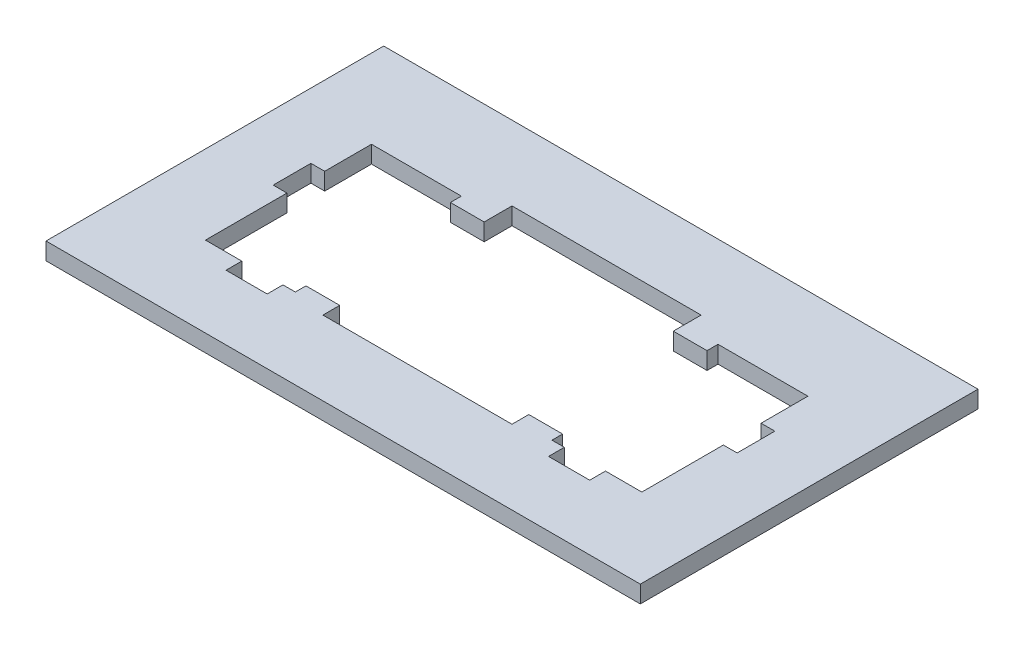
from build123d import *

# Parameters (mm, degrees)
SKETCH1_W           = 44
SKETCH1_H           = 25
BOSS_EXTRUDE1_DEPTH = 1.524
CHAMFER1_SIZE       = 0.25


with BuildPart() as part:
    # Sketch1 → Boss-Extrude1 (new body)
    with BuildSketch(Plane(origin=(0, 0, 0), x_dir=(1, 0, 0), z_dir=(0, 1, 0))):
        Rectangle(SKETCH1_W, SKETCH1_H)
        Polygon((-9.4996, 4.939226775), (-7, 4.939226775), (-7, 7), (7, 7), (7, 4.939226775), (9.4996, 4.939226775), (9.4996, 5.752026775), (16.1544, 5.752026775), (16.1544, 2.286), (17.174185585, 2.286), (17.174185585, -0.508), (16.1544, -0.508), (16.1544, -6.541573225), (13.462, -6.541573225), (13.462, -7.709973225), (10.414, -7.709973225), (10.414, -6.541573225), (9.4996, -6.541573225), (9.4996, -5.754173225), (7, -5.754173225), (7, -7), (-7, -7), (-7, -5.754173225), (-9.4996, -5.754173225), (-9.4996, -6.541573225), (-10.414, -6.541573225), (-10.414, -7.709973225), (-13.462, -7.709973225), (-13.462, -6.541573225), (-16.1544, -6.541573225), (-16.1544, -0.508), (-17.174185585, -0.508), (-17.174185585, 2.286), (-16.1544, 2.286), (-16.1544, 5.752026775), (-9.4996, 5.752026775), align=None, mode=Mode.SUBTRACT)
    extrude(amount=BOSS_EXTRUDE1_DEPTH)

    # Chamfer1
    chamfer1_edges = [part.edges().sort_by_distance(p)[0] for p in [
        (7, 0, -5.969613387),
        (0, 0, -7),
        (-7, 0, -5.969613387),
        (-8.2498, 0, -4.939226775),
        (-9.4996, 0, -5.345626775),
        (-12.827, 0, -5.752026775),
        (-16.1544, 0, -4.019013387),
        (-16.664292792, 0, -2.286),
        (-17.174185585, 0, -0.889),
        (-16.664292792, 0, 0.508),
        (-16.1544, 0, 3.524786613),
        (-14.8082, 0, 6.541573225),
        (-13.462, 0, 7.125773225),
        (-11.938, 0, 7.709973225),
        (-10.414, 0, 7.125773225),
        (-9.9568, 0, 6.541573225),
        (-9.4996, 0, 6.147873225),
        (-8.2498, 0, 5.754173225),
        (-7, 0, 6.377086613),
        (0, 0, 7),
        (7, 0, 6.377086613),
        (8.2498, 0, 5.754173225),
        (9.4996, 0, 6.147873225),
        (9.9568, 0, 6.541573225),
        (10.414, 0, 7.125773225),
        (11.938, 0, 7.709973225),
        (13.462, 0, 7.125773225),
        (14.8082, 0, 6.541573225),
        (16.1544, 0, 3.524786613),
        (16.664292792, 0, 0.508),
        (17.174185585, 0, -0.889),
        (16.664292792, 0, -2.286),
        (16.1544, 0, -4.019013387),
        (12.827, 0, -5.752026775),
        (9.4996, 0, -5.345626775),
        (8.2498, 0, -4.939226775),
        (0, 0, 12.5),
        (-22, 0, 0),
        (0, 0, -12.5),
        (22, 0, 0),
    ]]
    chamfer(chamfer1_edges, length=CHAMFER1_SIZE)


solid = part.part
